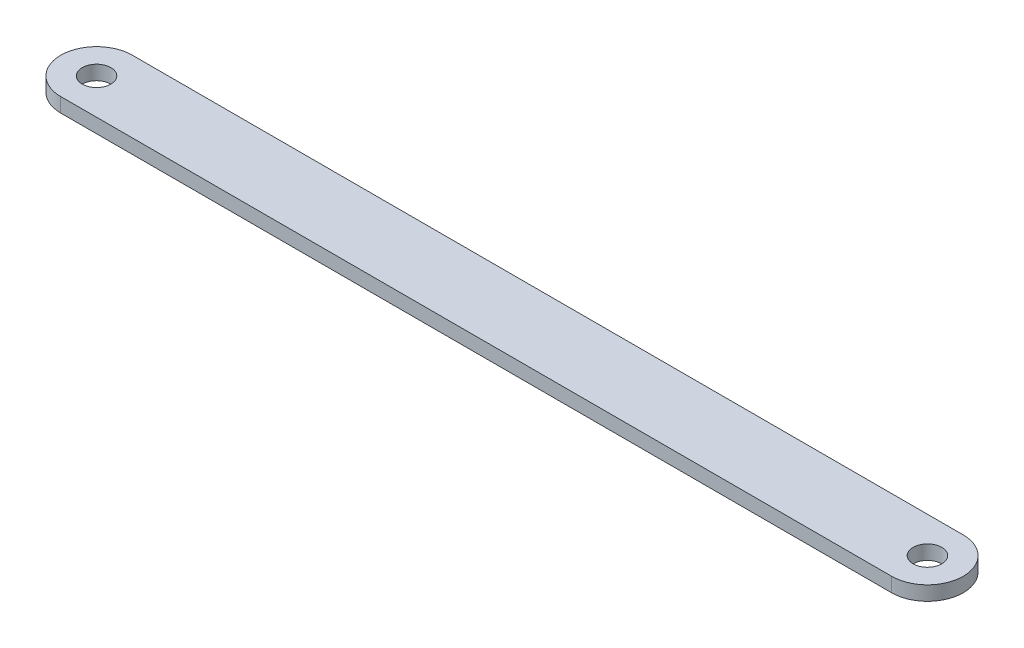
from build123d import *

# Parameters (mm, degrees)
SKETCH1_R           = 2
BOSS_EXTRUDE1_DEPTH = 2


with BuildPart() as part:
    # Sketch1 → Boss-Extrude1 (new body)
    with BuildSketch(Plane(origin=(0, 0, 0), x_dir=(1, 0, 0), z_dir=(0, 1, 0))):
        with BuildLine():
            Line((-58, 5), (58, 5))
            ThreePointArc((58, 5), (63, 0), (58, -5))
            Line((58, -5), (-58, -5))
            ThreePointArc((-58, -5), (-63, 0), (-58, 5))
        make_face()
        with Locations((-58, 0)):
            Circle(SKETCH1_R, mode=Mode.SUBTRACT)
        with Locations((58, 0)):
            Circle(SKETCH1_R, mode=Mode.SUBTRACT)
    extrude(amount=BOSS_EXTRUDE1_DEPTH)


solid = part.part
